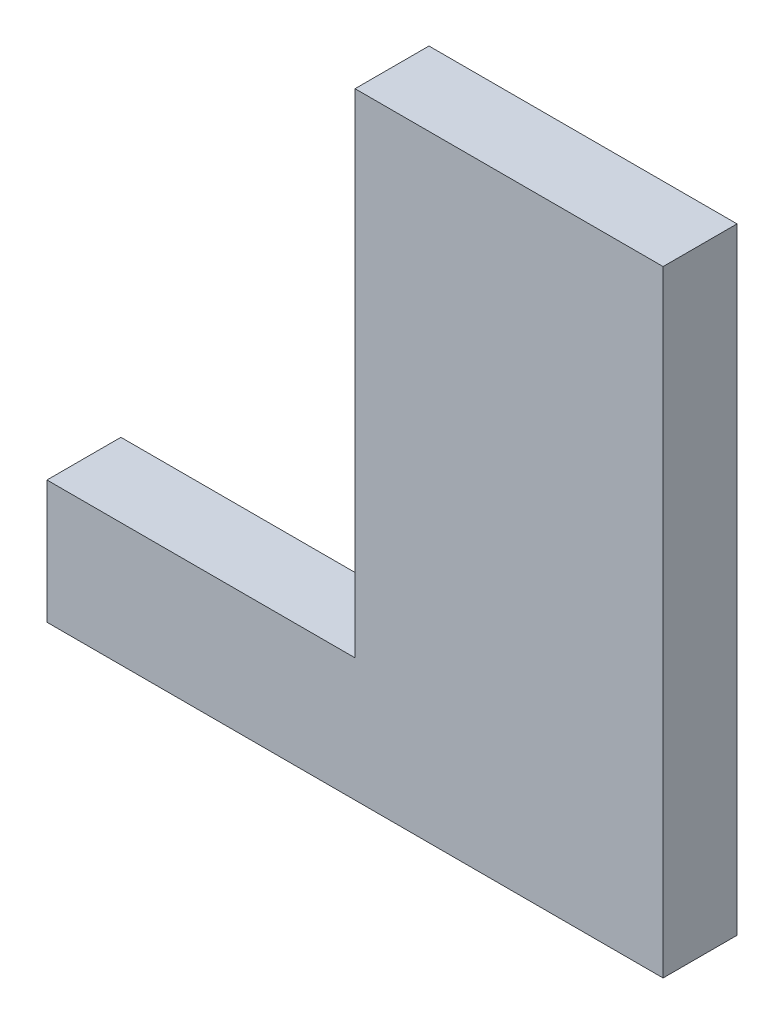
from build123d import *

# Parameters (mm, degrees)
SKETCH1_W           = 12.5
SKETCH1_H           = 3
BOSS_EXTRUDE1_DEPTH = 25
SKETCH1_3_W         = 12.5
SKETCH1_3_H         = 3
BOSS_EXTRUDE2_DEPTH = 5


with BuildPart() as part:
    # Sketch1 → Boss-Extrude1 (new body)
    with BuildSketch(Plane(origin=(0, 0, 0), x_dir=(1, 0, 0), z_dir=(0, 1, 0))):
        with Locations((6.25, 0)):
            Rectangle(SKETCH1_W, SKETCH1_H)
    extrude(amount=BOSS_EXTRUDE1_DEPTH)

    # Sketch1_3 → Boss-Extrude2 (add)
    with BuildSketch(Plane(origin=(0, 0, 0), x_dir=(1, 0, 0), z_dir=(0, 1, 0))):
        with Locations((-6.25, 0)):
            Rectangle(SKETCH1_3_W, SKETCH1_3_H)
    extrude(amount=BOSS_EXTRUDE2_DEPTH)


solid = part.part
